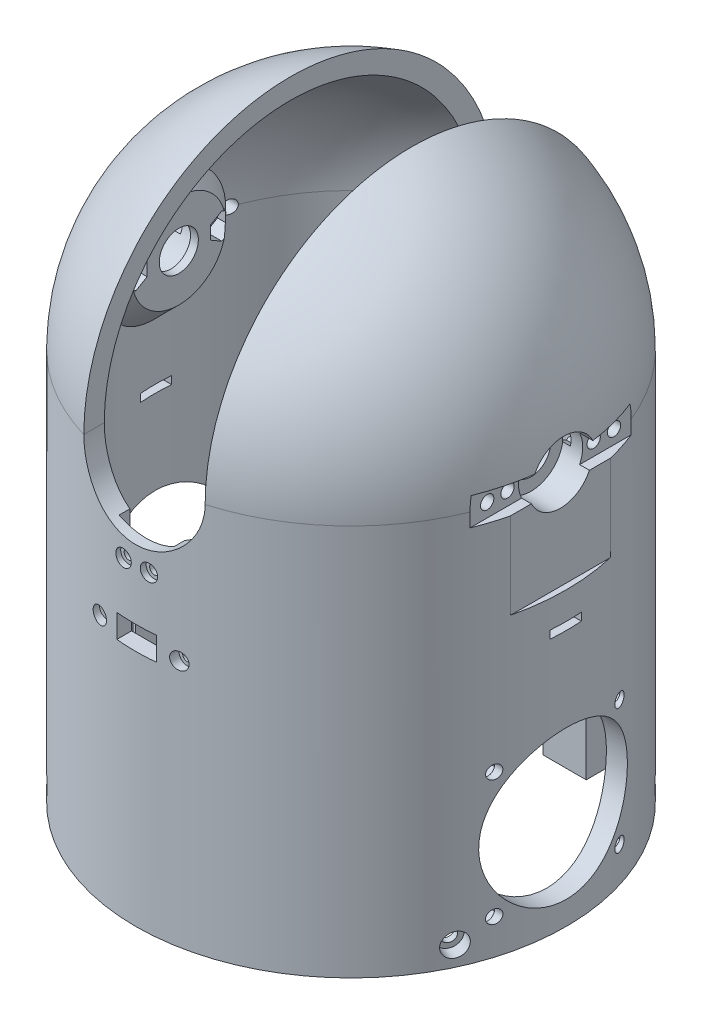
from build123d import *

# Parameters (mm, degrees)
CORTAR_EXTRUIR1_DEPTH      = 84
CORTAR_EXTRUIR1_DEPTH_BACK = 95
CROQUIS4_R                 = 5
CORTAR_EXTRUIR2_DEPTH      = 26
CROQUIS5_R                 = 8.2
CORTAR_EXTRUIR3_DEPTH      = 9
CROQUIS6_W                 = 50
CROQUIS6_H                 = 7
CORTAR_EXTRUIR4_DEPTH      = 4
CROQUIS7_R                 = 1.7
CORTAR_EXTRUIR5_DEPTH      = 10
CORTAR_EXTRUIR6_DEPTH      = 4
SALIENTE_EXTRUIR1_DEPTH    = 55
CORTAR_EXTRUIR7_DEPTH      = 55
MATRIZC1_COUNT             = 2
CROQUIS11_R                = 1.7
CORTAR_EXTRUIR8_DEPTH      = 10
CROQUIS12_R                = 2.95
CORTAR_EXTRUIR9_DEPTH      = 3.35
MATRIZC2_COUNT             = 2
MATRIZC2_ANGLE             = 290
MATRIZC3_COUNT             = 2
MATRIZC3_COPY_1_SKETCH_R   = 1.7
MATRIZC3_COPY_1_DEPTH      = 10
MATRIZC3_COPY_2_SKETCH_R   = 2.95
MATRIZC3_COPY_2_DEPTH      = 3.35
CROQUIS13_W                = 14
CROQUIS13_H                = 30
CORTAR_EXTRUIR10_DEPTH     = 52.25
CROQUIS14_R                = 1.2
CORTAR_EXTRUIR11_DEPTH     = 7.25
CROQUIS15_R                = 2.1
CORTAR_EXTRUIR12_DEPTH     = 1.5
CROQUIS16_W                = 27
CROQUIS16_H                = 12
CORTAR_EXTRUIR13_DEPTH     = 51
CROQUIS17_R                = 1.2
CROQUIS17_W                = 10.15
CROQUIS17_H                = 6
CORTAR_EXTRUIR14_DEPTH     = 6
CROQUIS18_R                = 2.1
CORTAR_EXTRUIR15_DEPTH     = 3
CROQUIS19_R                = 1.7
CROQUIS19_R_2              = 19
CORTAR_EXTRUIR16_DEPTH     = 11
CORTAR_EXTRUIR17_DEPTH     = 51
CORTAR_EXTRUIR18_DEPTH     = 1.5
CROQUIS22_W                = 8
CROQUIS22_H                = 2
CORTAR_EXTRUIR19_DEPTH     = 10


with BuildPart() as part:
    # Croquis1 → Revolución1 (revolve)
    with BuildSketch(Plane.XY):
        with BuildLine():
            Line((50, 100), (50, 0))
            Line((50, 0), (55, 0))
            Line((55, 0), (55, 100))
            ThreePointArc((55, 100), (38.890872965, 138.890872965), (0, 155))
            Line((0, 155), (0, 150))
            ThreePointArc((0, 150), (35.355339059, 135.355339059), (50, 100))
        make_face()
    revolve(axis=Axis((0, 176.429466528, 0), (0, -1, 0)))

    # Croquis2 → Cortar-Extruir1 (cut, two sides)
    with BuildSketch(Plane.XY) as cortar_extruir1_sk:
        with BuildLine():
            Line((15.5, 100), (15.5, 160))
            Line((15.5, 160), (-15.5, 160))
            Line((-15.5, 160), (-15.5, 100))
            ThreePointArc((-15.5, 100), (0, 84.5), (15.5, 100))
        make_face()
    extrude(amount=CORTAR_EXTRUIR1_DEPTH, mode=Mode.SUBTRACT)
    extrude(cortar_extruir1_sk.sketch, amount=-CORTAR_EXTRUIR1_DEPTH_BACK, mode=Mode.SUBTRACT)

    # Croquis3 → Revolución2 (revolve)
    with BuildSketch(Plane.XY):
        Polygon((-50, 118), (-50, 100), (-44, 100), (-44, 112), align=None)
    revoluci_n2 = revolve(axis=Axis((-69.509607383, 100, 0), (1, 0, 0)))

    # Croquis4 → Cortar-Extruir2 (cut)
    with BuildSketch(Plane(origin=(-44, 0, 0), x_dir=(0, 0, -1), z_dir=(1, 0, 0))):
        with Locations((0, 100)):
            Circle(CROQUIS4_R)
    cortar_extruir2 = extrude(amount=-CORTAR_EXTRUIR2_DEPTH, mode=Mode.SUBTRACT)

    # Croquis5 → Cortar-Extruir3 (cut)
    with BuildSketch(Plane.ZY.offset(55)):
        with Locations((0, 100)):
            Circle(CROQUIS5_R)
    cortar_extruir3 = extrude(amount=-CORTAR_EXTRUIR3_DEPTH, mode=Mode.SUBTRACT)

    # Croquis6 → Cortar-Extruir4 (cut)
    with BuildSketch(Plane.ZY.offset(55)):
        with Locations((0, 100)):
            Rectangle(CROQUIS6_W, CROQUIS6_H)
    cortar_extruir4 = extrude(amount=-CORTAR_EXTRUIR4_DEPTH, mode=Mode.SUBTRACT)

    # Croquis7 → Cortar-Extruir5 (cut)
    with BuildSketch(Plane.ZY.offset(51)):
        with Locations((-11, 100)):
            Circle(CROQUIS7_R)
        with Locations((11, 100)):
            Circle(CROQUIS7_R)
        with Locations((16.2, 100)):
            Circle(CROQUIS7_R)
        with Locations((-16.2, 100)):
            Circle(CROQUIS7_R)
    cortar_extruir5 = extrude(amount=-CORTAR_EXTRUIR5_DEPTH, mode=Mode.SUBTRACT)

    # Croquis8 → Cortar-Extruir6 (cut)
    with BuildSketch(Plane(origin=(-44, 0, 0), x_dir=(0, 0, -1), z_dir=(1, 0, 0))):
        Polygon((-11, 96.65), (-8.098814897, 98.325), (-8.098814897, 101.675), (-11, 103.35), (-13.901185103, 101.675), (-13.901185103, 98.325), align=None)
        Polygon((11, 96.65), (13.901185103, 98.325), (13.901185103, 101.675), (11, 103.35), (8.098814897, 101.675), (8.098814897, 98.325), align=None)
    cortar_extruir6 = extrude(amount=-CORTAR_EXTRUIR6_DEPTH, mode=Mode.SUBTRACT)

    # Simetría1: Revolución2, Cortar-Extruir2, Cortar-Extruir3, Cortar-Extruir4, Cortar-Extruir5, Cortar-Extruir6 across plane
    add(revoluci_n2.mirror(Plane(origin=(0, 0, 0), x_dir=(0, 0, 1), z_dir=(1, 0, 0))))
    add(cortar_extruir2.mirror(Plane(origin=(0, 0, 0), x_dir=(0, 0, 1), z_dir=(1, 0, 0))), mode=Mode.SUBTRACT)
    add(cortar_extruir3.mirror(Plane(origin=(0, 0, 0), x_dir=(0, 0, 1), z_dir=(1, 0, 0))), mode=Mode.SUBTRACT)
    add(cortar_extruir4.mirror(Plane(origin=(0, 0, 0), x_dir=(0, 0, 1), z_dir=(1, 0, 0))), mode=Mode.SUBTRACT)
    add(cortar_extruir5.mirror(Plane(origin=(0, 0, 0), x_dir=(0, 0, 1), z_dir=(1, 0, 0))), mode=Mode.SUBTRACT)
    add(cortar_extruir6.mirror(Plane(origin=(0, 0, 0), x_dir=(0, 0, 1), z_dir=(1, 0, 0))), mode=Mode.SUBTRACT)

    # Croquis9 → Saliente-Extruir1 (add)
    with BuildSketch(Plane.XZ):
        with BuildLine():
            Line((-38.9, -27), (-27.9, -27))
            Line((-27.9, -27), (-27.9, -41.492047431))
            ThreePointArc((-27.9, -41.492047431), (-33.778036088, -36.865217727), (-38.9, -31.41321378))
            Line((-38.9, -31.41321378), (-38.9, -27))
        make_face()
        with BuildLine():
            Line((14.1, -35), (25.1, -35))
            Line((25.1, -35), (25.1, -43.243380996))
            ThreePointArc((25.1, -43.243380996), (19.742009373, -45.937490854), (14.1, -47.970720236))
            Line((14.1, -47.970720236), (14.1, -35))
        make_face()
    saliente_extruir1 = extrude(amount=-SALIENTE_EXTRUIR1_DEPTH)

    # Croquis10 → Cortar-Extruir7 (cut)
    with BuildSketch(Plane.XZ):
        Polygon((-27.9, -41.492047431), (-21.056531053, -41.492047431), (-21.056531053, -45.35), (-24.1, -45.35), (-27.9, -43), align=None)
        Polygon((-32, -29.5), (-32, -39.5), (-26.041232037, -34.5), align=None)
        Polygon((18.2, -37.5), (18.2, -47.5), (12.241232037, -42.5), align=None)
    cortar_extruir7 = extrude(amount=-CORTAR_EXTRUIR7_DEPTH, mode=Mode.SUBTRACT)

    # MatrizC1: Saliente-Extruir1, Cortar-Extruir7 ×2 about axis
    matrizc1_axis = Axis((0, 0, 0), (0, 1, 0))
    for i in range(1, MATRIZC1_COUNT):
        add(saliente_extruir1.rotate(matrizc1_axis, i * 360 / MATRIZC1_COUNT))
        add(cortar_extruir7.rotate(matrizc1_axis, i * 360 / MATRIZC1_COUNT), mode=Mode.SUBTRACT)

    # Croquis11 → Cortar-Extruir8 (cut)
    with BuildSketch(Plane(origin=(-38.890872965, 0, 38.890872965), x_dir=(0, 1, 0), z_dir=(-0.707106781, 0, 0.707106781))):
        with Locations((5, 0)):
            Circle(CROQUIS11_R)
    cortar_extruir8 = extrude(amount=-CORTAR_EXTRUIR8_DEPTH, mode=Mode.SUBTRACT)

    # Croquis12 → Cortar-Extruir9 (cut)
    with BuildSketch(Plane(origin=(-38.890872965, 0, 38.890872965), x_dir=(0, 1, 0), z_dir=(-0.707106781, 0, 0.707106781))):
        with Locations((5, 0)):
            Circle(CROQUIS12_R)
    cortar_extruir9 = extrude(amount=-CORTAR_EXTRUIR9_DEPTH, mode=Mode.SUBTRACT)

    # MatrizC2: Cortar-Extruir8, Cortar-Extruir9 ×2 about axis
    matrizc2_axis = Axis((0, 0, 0), (0, 1, 0))
    for i in range(1, MATRIZC2_COUNT):
        add(cortar_extruir8.rotate(matrizc2_axis, i * MATRIZC2_ANGLE / (MATRIZC2_COUNT - 1)), mode=Mode.SUBTRACT)
        add(cortar_extruir9.rotate(matrizc2_axis, i * MATRIZC2_ANGLE / (MATRIZC2_COUNT - 1)), mode=Mode.SUBTRACT)

    # MatrizC3: Cortar-Extruir8, Cortar-Extruir9 ×2 about axis
    matrizc3_axis = Axis((0, 0, 0), (0, 1, 0))
    for i in range(1, MATRIZC3_COUNT):
        add(cortar_extruir8.rotate(matrizc3_axis, i * 360 / MATRIZC3_COUNT), mode=Mode.SUBTRACT)
        add(cortar_extruir9.rotate(matrizc3_axis, i * 360 / MATRIZC3_COUNT), mode=Mode.SUBTRACT)

    # MatrizC3 copy 1 sketch → MatrizC3 copy 1 (cut)
    with BuildSketch(Plane(origin=(49.846928287, 0, 23.244004396), x_dir=(0, 1, 0), z_dir=(0.906307787, 0, 0.422618262))):
        with Locations((5, 0)):
            Circle(MATRIZC3_COPY_1_SKETCH_R)
    extrude(amount=-MATRIZC3_COPY_1_DEPTH, mode=Mode.SUBTRACT)

    # MatrizC3 copy 2 sketch → MatrizC3 copy 2 (cut)
    with BuildSketch(Plane(origin=(49.846928287, 0, 23.244004396), x_dir=(0, 1, 0), z_dir=(0.906307787, 0, 0.422618262))):
        with Locations((5, 0)):
            Circle(MATRIZC3_COPY_2_SKETCH_R)
    extrude(amount=-MATRIZC3_COPY_2_DEPTH, mode=Mode.SUBTRACT)

    # Croquis13 → Cortar-Extruir10 (cut)
    with BuildSketch(Plane.XY):
        with Locations((0, 87)):
            Rectangle(CROQUIS13_W, CROQUIS13_H)
    extrude(amount=CORTAR_EXTRUIR10_DEPTH, mode=Mode.SUBTRACT)

    # Croquis14 → Cortar-Extruir11 (cut)
    with BuildSketch(Plane(origin=(0, 0, 52.25), x_dir=(-1, 0, 0), z_dir=(0, 0, -1))):
        with Locations((-3.25, 79.9)):
            Circle(CROQUIS14_R)
        with Locations((3.25, 79.9)):
            Circle(CROQUIS14_R)
    extrude(amount=-CORTAR_EXTRUIR11_DEPTH, mode=Mode.SUBTRACT)

    # Croquis15 → Cortar-Extruir12 (cut)
    with BuildSketch(Plane.XY.offset(55)):
        with Locations((-3.25, 79.9)):
            Circle(CROQUIS15_R)
        with Locations((3.25, 79.9)):
            Circle(CROQUIS15_R)
    extrude(amount=-CORTAR_EXTRUIR12_DEPTH, mode=Mode.SUBTRACT)

    # Croquis16 → Cortar-Extruir13 (cut)
    with BuildSketch(Plane.XY):
        with Locations((0, 63.375)):
            Rectangle(CROQUIS16_W, CROQUIS16_H)
    extrude(amount=CORTAR_EXTRUIR13_DEPTH, mode=Mode.SUBTRACT)

    # Croquis17 → Cortar-Extruir14 (cut)
    with BuildSketch(Plane(origin=(0, 0, 51), x_dir=(-1, 0, 0), z_dir=(0, 0, -1))):
        with Locations((-10.16, 63.375)):
            Circle(CROQUIS17_R)
        with Locations((10.16, 63.375)):
            Circle(CROQUIS17_R)
        with Locations((0, 63.875)):
            Rectangle(CROQUIS17_W, CROQUIS17_H)
    extrude(amount=-CORTAR_EXTRUIR14_DEPTH, mode=Mode.SUBTRACT)

    # Croquis18 → Cortar-Extruir15 (cut)
    with BuildSketch(Plane.XY.offset(55)):
        with Locations((-10.16, 63.375)):
            Circle(CROQUIS18_R)
        with Locations((10.16, 63.375)):
            Circle(CROQUIS18_R)
    extrude(amount=-CORTAR_EXTRUIR15_DEPTH, mode=Mode.SUBTRACT)

    # Croquis19 → Cortar-Extruir16 (cut)
    with BuildSketch(Plane.ZY.offset(55)):
        with Locations((-16, 41)):
            Circle(CROQUIS19_R)
        with Locations((16, 41)):
            Circle(CROQUIS19_R)
        with Locations((-16, 9)):
            Circle(CROQUIS19_R)
        with Locations((16, 9)):
            Circle(CROQUIS19_R)
        with Locations((0, 25)):
            Circle(CROQUIS19_R_2)
    cortar_extruir16 = extrude(amount=-CORTAR_EXTRUIR16_DEPTH, mode=Mode.SUBTRACT)

    # Croquis20 → Cortar-Extruir17 (cut)
    with BuildSketch(Plane(origin=(0, 0, 0), x_dir=(0, 0, -1), z_dir=(1, 0, 0))):
        Polygon((-16, 37.65), (-13.098814897, 39.325), (-13.098814897, 42.675), (-16, 44.35), (-18.901185103, 42.675), (-18.901185103, 39.325), align=None)
        Polygon((16, 37.65), (18.901185103, 39.325), (18.901185103, 42.675), (16, 44.35), (13.098814897, 42.675), (13.098814897, 39.325), align=None)
        Polygon((16, 5.65), (18.901185103, 7.325), (18.901185103, 10.675), (16, 12.35), (13.098814897, 10.675), (13.098814897, 7.325), align=None)
        Polygon((-16, 5.65), (-13.098814897, 7.325), (-13.098814897, 10.675), (-16, 12.35), (-18.901185103, 10.675), (-18.901185103, 7.325), align=None)
    cortar_extruir17 = extrude(amount=-CORTAR_EXTRUIR17_DEPTH, mode=Mode.SUBTRACT)

    # Simetría2: Cortar-Extruir16, Cortar-Extruir17 across plane
    add(cortar_extruir16.mirror(Plane(origin=(0, 0, 0), x_dir=(0, 0, 1), z_dir=(1, 0, 0))), mode=Mode.SUBTRACT)
    add(cortar_extruir17.mirror(Plane(origin=(0, 0, 0), x_dir=(0, 0, 1), z_dir=(1, 0, 0))), mode=Mode.SUBTRACT)

    # Croquis21 → Cortar-Extruir18 (cut)
    with BuildSketch(Plane.ZY.offset(55)):
        with BuildLine():
            Line((-16.25, 96.5), (-3.570714214, 96.5))
            ThreePointArc((-3.570714214, 96.5), (0, 95), (3.570714214, 96.5))
            Line((3.570714214, 96.5), (16.25, 96.5))
            Line((16.25, 96.5), (16.25, 74.5))
            Line((16.25, 74.5), (-16.25, 74.5))
            Line((-16.25, 74.5), (-16.25, 96.5))
        make_face()
    cortar_extruir18 = extrude(amount=-CORTAR_EXTRUIR18_DEPTH, mode=Mode.SUBTRACT)

    # Croquis22 → Cortar-Extruir19 (cut)
    with BuildSketch(Plane.ZY.offset(55)):
        with Locations((0, 66.5)):
            Rectangle(CROQUIS22_W, CROQUIS22_H)
    cortar_extruir19 = extrude(amount=-CORTAR_EXTRUIR19_DEPTH, mode=Mode.SUBTRACT)

    # Simetría3: Cortar-Extruir18, Cortar-Extruir19 across plane
    add(cortar_extruir18.mirror(Plane(origin=(0, 0, 0), x_dir=(0, 0, 1), z_dir=(1, 0, 0))), mode=Mode.SUBTRACT)
    add(cortar_extruir19.mirror(Plane(origin=(0, 0, 0), x_dir=(0, 0, 1), z_dir=(1, 0, 0))), mode=Mode.SUBTRACT)


solid = part.part
